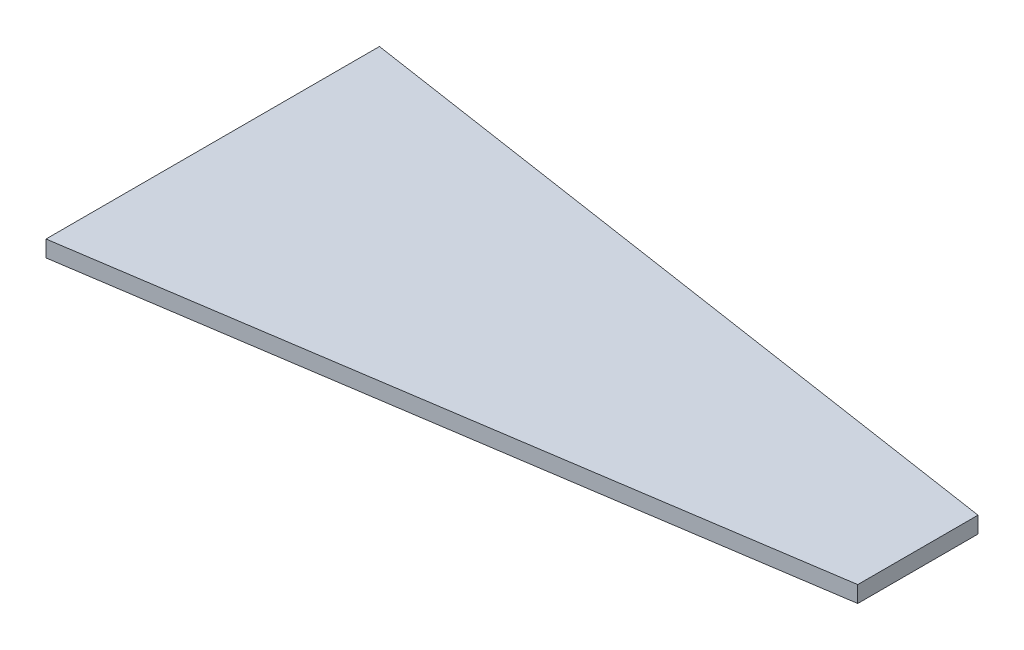
from build123d import *

# Parameters (mm, degrees)
BOSS_EXTRUDE1_DEPTH = 3


with BuildPart() as part:
    # Sketch1 → Boss-Extrude1 (new body)
    with BuildSketch(Plane(origin=(0, 0, 0), x_dir=(1, 0, 0), z_dir=(0, 1, 0))):
        Polygon((0, 30.5), (0, -30.5), (129, -11), (129, 11), align=None)
    extrude(amount=BOSS_EXTRUDE1_DEPTH)


solid = part.part
